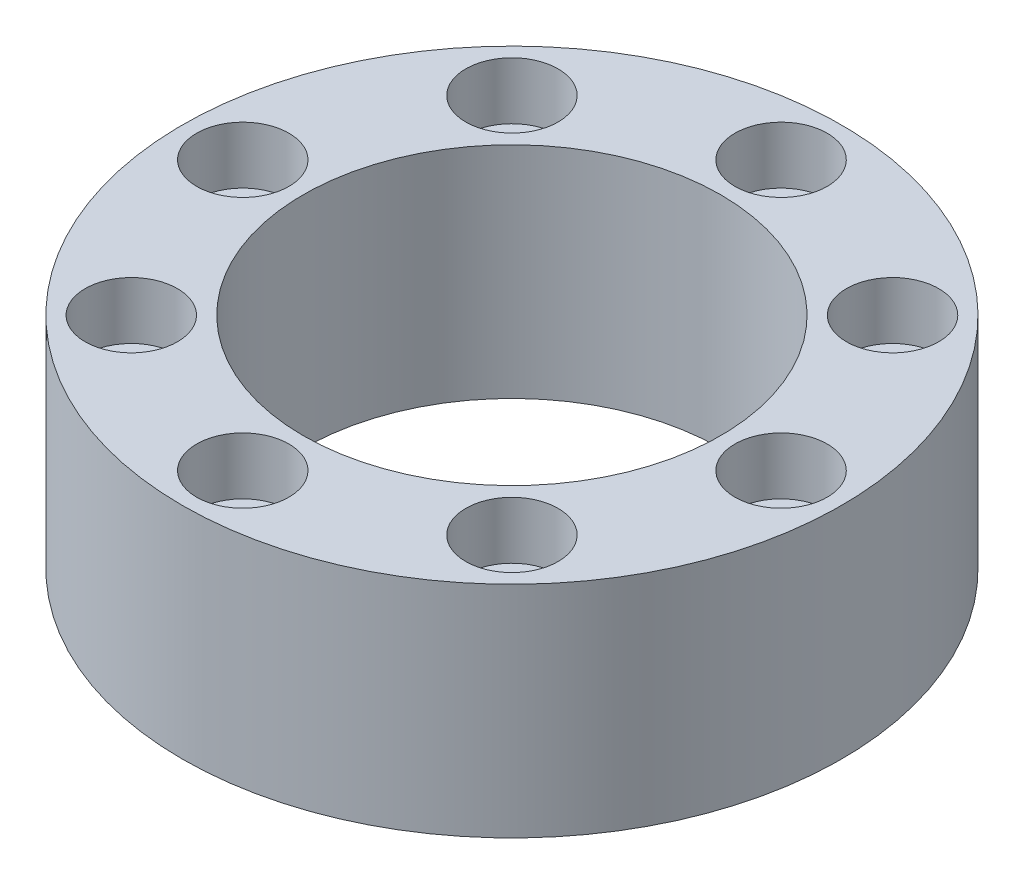
from build123d import *

# Parameters (mm, degrees)
ESQUISSE1_R             = 30
ESQUISSE1_R_2           = 19
BOSS_EXTRU_2_DEPTH      = 20
ESQUISSE5_R             = 2.55
ENL_V_MAT_EXTRU_3_DEPTH = 21
ESQUISSE6_R             = 4.2
ENL_V_MAT_EXTRU_4_DEPTH = 5.2


with BuildPart() as part:
    # Esquisse1 → Boss.-Extru.2 (new body)
    with BuildSketch(Plane(origin=(0, 0, 0), x_dir=(1, 0, 0), z_dir=(0, 1, 0))):
        Circle(ESQUISSE1_R)
        Circle(ESQUISSE1_R_2, mode=Mode.SUBTRACT)
    extrude(amount=BOSS_EXTRU_2_DEPTH)

    # Esquisse5 → Enlèv. mat.-Extru.3 (cut, through all)
    with BuildSketch(Plane(origin=(0, 20, 0), x_dir=(1, 0, 0), z_dir=(0, 1, 0))):
        with Locations((24.5, 0)):
            Circle(ESQUISSE5_R)
        with Locations((17.324116139, -17.324116139)):
            Circle(ESQUISSE5_R)
        with Locations((0, -24.5)):
            Circle(ESQUISSE5_R)
        with Locations((-17.324116139, -17.324116139)):
            Circle(ESQUISSE5_R)
        with Locations((-24.5, 0)):
            Circle(ESQUISSE5_R)
        with Locations((-17.324116139, 17.324116139)):
            Circle(ESQUISSE5_R)
        with Locations((0, 24.5)):
            Circle(ESQUISSE5_R)
        with Locations((17.324116139, 17.324116139)):
            Circle(ESQUISSE5_R)
    extrude(amount=-ENL_V_MAT_EXTRU_3_DEPTH, mode=Mode.SUBTRACT)

    # Esquisse6 → Enlèv. mat.-Extru.4 (cut)
    with BuildSketch(Plane(origin=(0, 20, 0), x_dir=(1, 0, 0), z_dir=(0, 1, 0))):
        with Locations((24.5, 0)):
            Circle(ESQUISSE6_R)
        with Locations((17.324116139, 17.324116139)):
            Circle(ESQUISSE6_R)
        with Locations((0, 24.5)):
            Circle(ESQUISSE6_R)
        with Locations((-17.324116139, 17.324116139)):
            Circle(ESQUISSE6_R)
        with Locations((-24.5, 0)):
            Circle(ESQUISSE6_R)
        with Locations((-17.324116139, -17.324116139)):
            Circle(ESQUISSE6_R)
        with Locations((0, -24.5)):
            Circle(ESQUISSE6_R)
        with Locations((17.324116139, -17.324116139)):
            Circle(ESQUISSE6_R)
    extrude(amount=-ENL_V_MAT_EXTRU_4_DEPTH, mode=Mode.SUBTRACT)


solid = part.part
